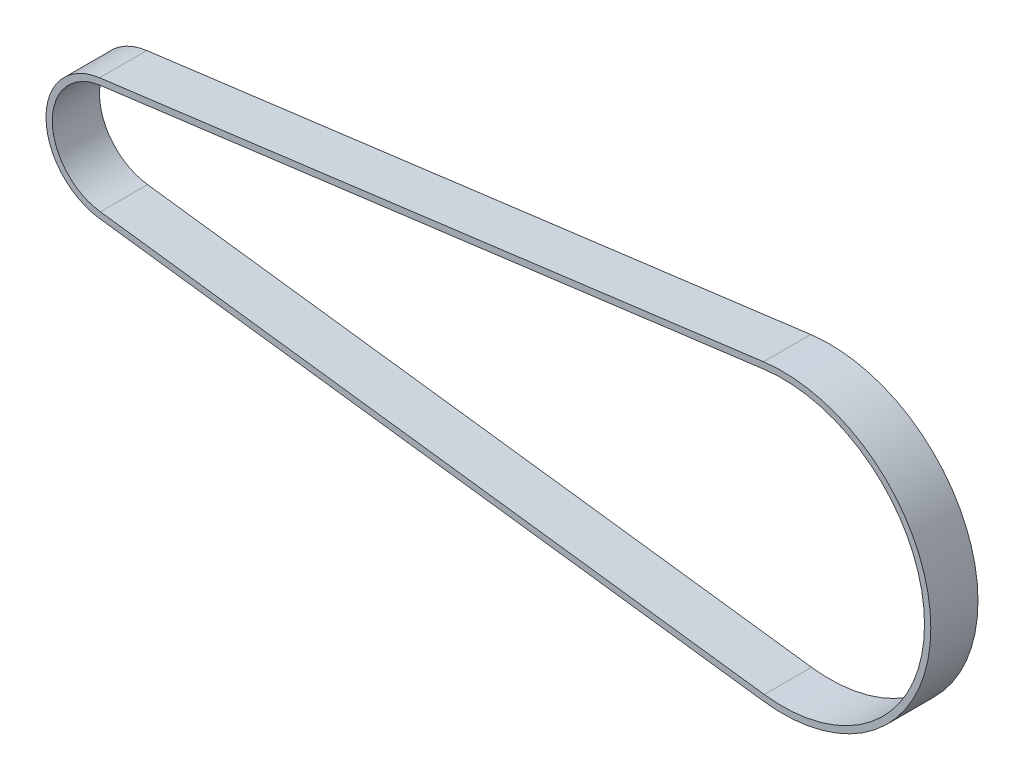
from build123d import *

# Parameters (mm, degrees)
EXTRUDE_THIN1_DEPTH      = 9.525
EXTRUDE_THIN1_DEPTH_BACK = 9.525


with BuildPart() as part:
    # Sketch1 → Extrude-Thin1 (new body, two sides)
    with BuildSketch(Plane.XY) as extrude_thin1_sk:
        with BuildLine():
            Line((264.851021428, -59.353801417), (-3.190403177, -24.621386578))
            ThreePointArc((-3.190403177, -24.621386578), (-24.82723, 0), (-3.190403177, 24.621386578))
            Line((-3.190403177, 24.621386578), (264.851021428, 59.353801417))
            ThreePointArc((264.851021428, 59.353801417), (332.39202, 0), (264.851021428, -59.353801417))
        make_face()
        with BuildLine():
            Line((265.17742208, -56.834860644), (-2.864002524, -22.102445806))
            ThreePointArc((-2.864002524, -22.102445806), (-22.28723, 0), (-2.864002524, 22.102445806))
            Line((-2.864002524, 22.102445806), (265.17742208, 56.834860644))
            ThreePointArc((265.17742208, 56.834860644), (329.85202, 0), (265.17742208, -56.834860644))
        make_face(mode=Mode.SUBTRACT)
    extrude(amount=EXTRUDE_THIN1_DEPTH)
    extrude(extrude_thin1_sk.sketch, amount=-EXTRUDE_THIN1_DEPTH_BACK)


solid = part.part
